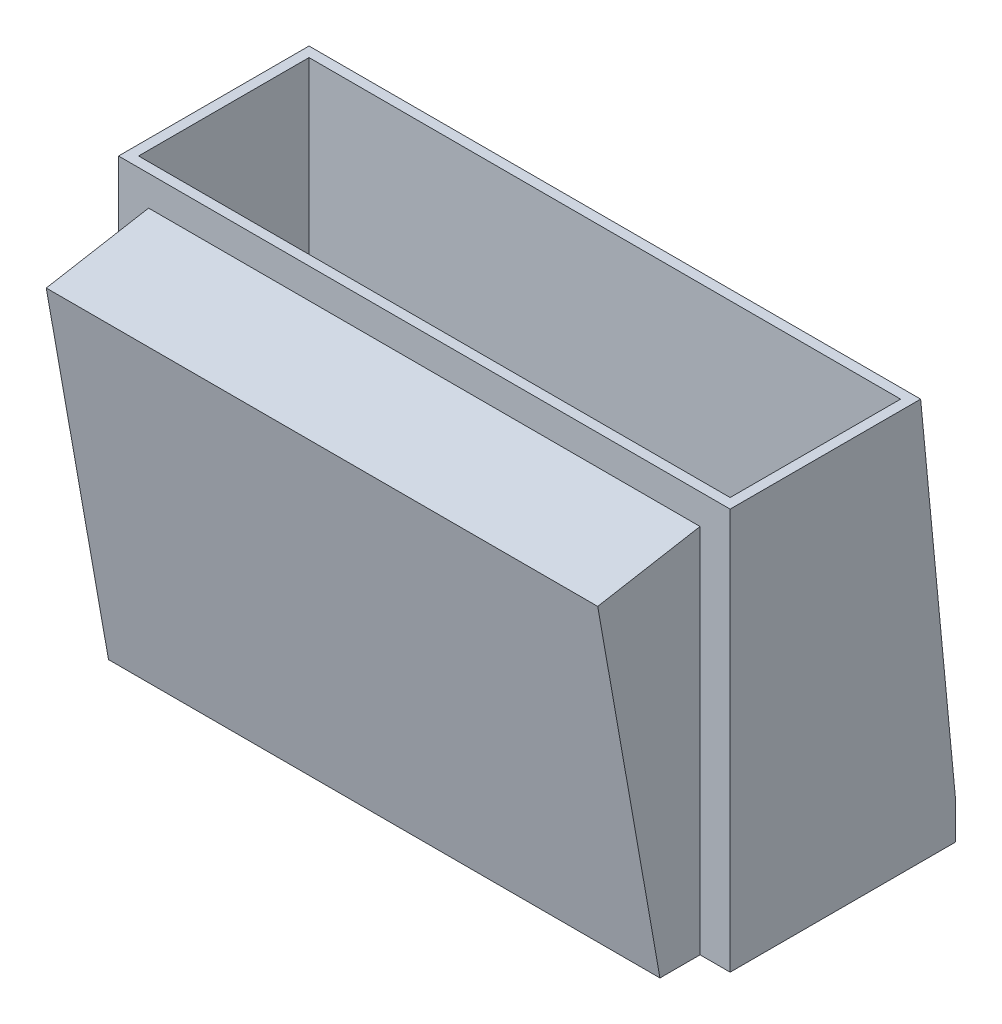
from build123d import *

# Parameters (mm, degrees)
SKETCH1_W           = 30.5
SKETCH1_H           = 9.5
SKETCH1_W_2         = 29.5
SKETCH1_H_2         = 8.5
BOSS_EXTRUDE1_DEPTH = 20
BOSS_EXTRUDE2_DEPTH = 30.5
CUT_EXTRUDE1_DEPTH  = 1.5


with BuildPart() as part:
    # Sketch1 → Boss-Extrude1 (new body)
    with BuildSketch(Plane(origin=(0, 0, 0), x_dir=(1, 0, 0), z_dir=(0, 1, 0))):
        Rectangle(SKETCH1_W, SKETCH1_H)
        Rectangle(SKETCH1_W_2, SKETCH1_H_2, mode=Mode.SUBTRACT)
    extrude(amount=BOSS_EXTRUDE1_DEPTH)

    # Sketch2 → Boss-Extrude2 (add)
    with BuildSketch(Plane.ZY.offset(15.25)):
        Polygon((6.75, 18.147346039), (6.75, 0), (9.853378947, 17.600136599), align=None)
        Polygon((4.75, 18.5), (4.75, 0), (6.75, 0), (6.75, 18.147346039), align=None)
        Polygon((-6.5, 1.75), (-4.75, 20), (-4.75, 0), (-6.5, 0), align=None)
    extrude(amount=-BOSS_EXTRUDE2_DEPTH)

    # Sketch3 → Cut-Extrude1 (cut)
    with BuildSketch(Plane.ZY.offset(15.25)):
        Polygon((4.75, 18.5), (9.853378947, 17.600136599), (6.75, 0), (4.75, 0), align=None)
    cut_extrude1 = extrude(amount=-CUT_EXTRUDE1_DEPTH, mode=Mode.SUBTRACT)

    # Mirror1: Cut-Extrude1 across plane
    add(cut_extrude1.mirror(Plane.ZY), mode=Mode.SUBTRACT)


solid = part.part
